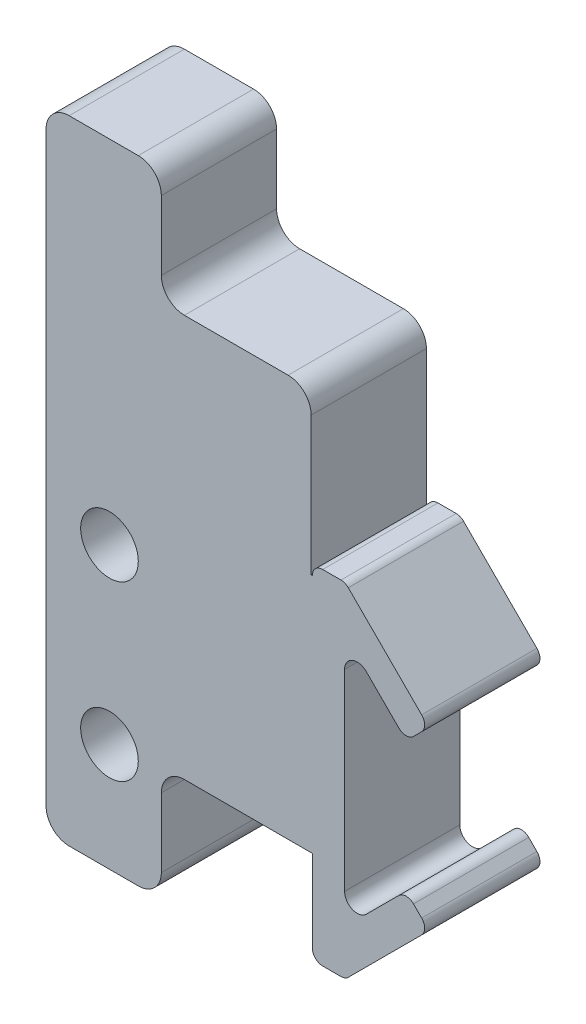
from build123d import *

# Parameters (mm, degrees)
ESQUISSE1_R        = 2.5
BOSS_EXTRU_1_DEPTH = 10
CONG_1_R           = 2


with BuildPart() as part:
    # Esquisse1 → Boss.-Extru.1 (new body)
    with BuildSketch(Plane.XY):
        with BuildLine():
            Line((0.1, 14), (0, 14))
            Line((0, 14), (0, 28))
            Line((0, 28), (-13, 28))
            Line((-13, 28), (-13, 38))
            Line((-13, 38), (-23, 38))
            Line((-23, 38), (-23, -16.88168582))
            Line((-23, -16.88168582), (-13, -16.88168582))
            Line((-13, -16.88168582), (-13, -6.88168582))
            Line((-13, -6.88168582), (0.1, -6.88168582))
            Line((0.1, -6.88168582), (0.1, -14))
            ThreePointArc((0.1, -14), (0.363603897, -14.636396103), (1, -14.9))
            Line((1, -14.9), (2.585786438, -14.9))
            ThreePointArc((2.585786438, -14.9), (2.930201527, -14.831491579), (3.222182541, -14.636396103))
            Line((3.222182541, -14.636396103), (9.586143571, -8.272435072))
            ThreePointArc((9.586143571, -8.272435072), (9.849747468, -7.636038969), (9.586143571, -6.999642866))
            Line((9.586143571, -6.999642866), (8.87903679, -6.292536085))
            ThreePointArc((8.87903679, -6.292536085), (8.242640687, -6.028932188), (7.606244584, -6.292536085))
            Line((7.606244584, -6.292536085), (4.777817459, -9.12096321))
            ThreePointArc((4.777817459, -9.12096321), (3.579048224, -9.359413236), (2.9, -8.343145751))
            Line((2.9, -8.343145751), (2.9, 8.343145751))
            ThreePointArc((2.9, 8.343145751), (3.579048224, 9.359413236), (4.777817459, 9.12096321))
            Line((4.777817459, 9.12096321), (7.606244584, 6.292536085))
            ThreePointArc((7.606244584, 6.292536085), (8.242640687, 6.028932188), (8.87903679, 6.292536085))
            Line((8.87903679, 6.292536085), (9.586143571, 6.999642866))
            ThreePointArc((9.586143571, 6.999642866), (9.849747468, 7.636038969), (9.586143571, 8.272435072))
            Line((9.586143571, 8.272435072), (3.222182541, 14.636396103))
            ThreePointArc((3.222182541, 14.636396103), (2.930201527, 14.831491579), (2.585786438, 14.9))
            Line((2.585786438, 14.9), (1, 14.9))
            ThreePointArc((1, 14.9), (0.363603897, 14.636396103), (0.1, 14))
        make_face()
        with Locations((-17.5, 7.5)):
            Circle(ESQUISSE1_R, mode=Mode.SUBTRACT)
        with Locations((-17.5, -7.5)):
            Circle(ESQUISSE1_R, mode=Mode.SUBTRACT)
    extrude(amount=BOSS_EXTRU_1_DEPTH)

    # Congé1
    cong_1_edges = [part.edges().sort_by_distance(p)[0] for p in [
        (-13, -6.88168582, 5),
        (-13, -16.88168582, 5),
        (-23, -16.88168582, 5),
        (-23, 38, 5),
        (-13, 38, 5),
        (-13, 28, 5),
        (0, 28, 5),
    ]]
    fillet(cong_1_edges, radius=CONG_1_R)


solid = part.part
